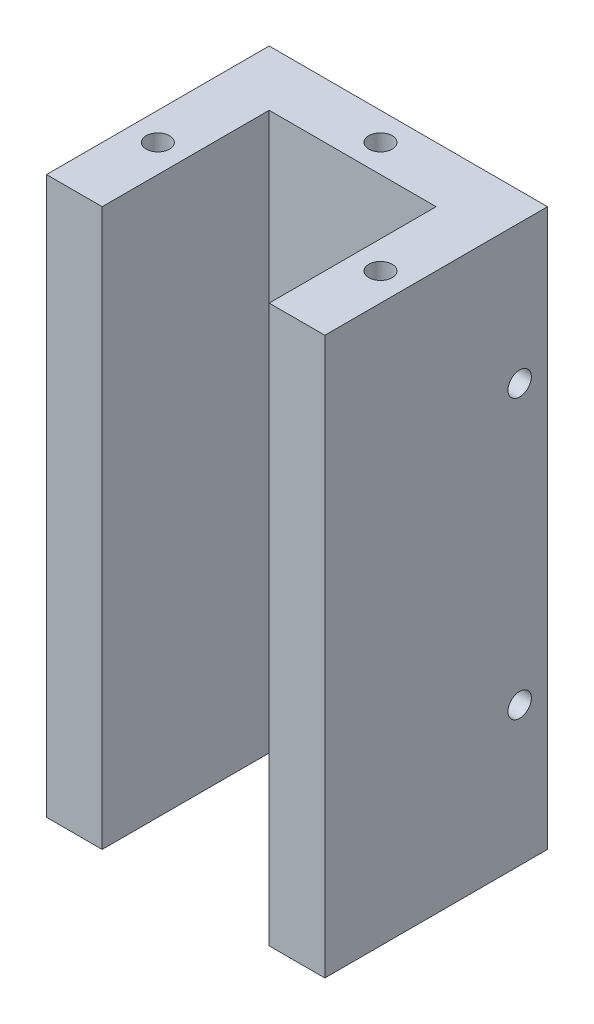
from build123d import *

# Parameters (mm, degrees)
SKETCH1_W                 = 50
SKETCH1_H                 = 40
BOSS_EXTRUDE1_DEPTH       = 100
SKETCH2_W                 = 30
SKETCH2_H                 = 30
CUT_EXTRUDE1_DEPTH        = 100
SKETCH3_R                 = 3.5
CUT_EXTRUDE2_DEPTH        = 10
M5X0_8_TAPPED_HOLE1_D     = 4.2
M5X0_8_TAPPED_HOLE1_DEPTH = 14
M5X0_8_TAPPED_HOLE1_TIP   = 1.2618073
M5X0_8_TAPPED_HOLE2_D     = 4.2
M5X0_8_TAPPED_HOLE2_DEPTH = 14
M5X0_8_TAPPED_HOLE2_TIP   = 1.2618073
M5X0_8_TAPPED_HOLE3_D     = 4.2
M5X0_8_TAPPED_HOLE3_DEPTH = 14
M5X0_8_TAPPED_HOLE3_TIP   = 1.2618073
M5X0_8_TAPPED_HOLE4_D     = 4.2
M5X0_8_TAPPED_HOLE4_DEPTH = 14
M5X0_8_TAPPED_HOLE4_TIP   = 1.2618073


with BuildPart() as part:
    # Sketch1 → Boss-Extrude1 (new body)
    with BuildSketch(Plane(origin=(0, 0, 0), x_dir=(1, 0, 0), z_dir=(0, 1, 0))):
        Rectangle(SKETCH1_W, SKETCH1_H)
    extrude(amount=BOSS_EXTRUDE1_DEPTH)

    # Sketch2 → Cut-Extrude1 (cut)
    with BuildSketch(Plane(origin=(0, 100, 0), x_dir=(1, 0, 0), z_dir=(0, 1, 0))):
        with Locations((0, -5)):
            Rectangle(SKETCH2_W, SKETCH2_H)
    extrude(amount=-CUT_EXTRUDE1_DEPTH, mode=Mode.SUBTRACT)

    # Sketch3 → Cut-Extrude2 (cut)
    with BuildSketch(Plane(origin=(0, 0, -20), x_dir=(-1, 0, 0), z_dir=(0, 0, -1))):
        with Locations((0, 25)):
            Circle(SKETCH3_R)
        with Locations((0, 75)):
            Circle(SKETCH3_R)
    extrude(amount=-CUT_EXTRUDE2_DEPTH, mode=Mode.SUBTRACT)

    # M5x0.8 Tapped Hole1
    with Locations(Plane.XZ):
        with Locations((0, -15), (-20, 5), (20, 5)):
            Hole(M5X0_8_TAPPED_HOLE1_D / 2, depth=M5X0_8_TAPPED_HOLE1_DEPTH)
            with Locations((0, 0, -(M5X0_8_TAPPED_HOLE1_DEPTH + M5X0_8_TAPPED_HOLE1_TIP / 2))):  # 118° drill point
                Cone(0, M5X0_8_TAPPED_HOLE1_D / 2, M5X0_8_TAPPED_HOLE1_TIP, mode=Mode.SUBTRACT)

    # M5x0.8 Tapped Hole2
    with Locations(Plane(origin=(0, 100, 0), x_dir=(-1, 0, 0), z_dir=(0, 1, 0))):
        with Locations((20, 5), (-20, 5), (0, -15)):
            Hole(M5X0_8_TAPPED_HOLE2_D / 2, depth=M5X0_8_TAPPED_HOLE2_DEPTH)
            with Locations((0, 0, -(M5X0_8_TAPPED_HOLE2_DEPTH + M5X0_8_TAPPED_HOLE2_TIP / 2))):  # 118° drill point
                Cone(0, M5X0_8_TAPPED_HOLE2_D / 2, M5X0_8_TAPPED_HOLE2_TIP, mode=Mode.SUBTRACT)

    # M5x0.8 Tapped Hole3
    with Locations(Plane(origin=(25, 0, 0), x_dir=(0, 0, -1), z_dir=(1, 0, 0))):
        with Locations((15, 75), (15, 25)):
            Hole(M5X0_8_TAPPED_HOLE3_D / 2, depth=M5X0_8_TAPPED_HOLE3_DEPTH)
            with Locations((0, 0, -(M5X0_8_TAPPED_HOLE3_DEPTH + M5X0_8_TAPPED_HOLE3_TIP / 2))):  # 118° drill point
                Cone(0, M5X0_8_TAPPED_HOLE3_D / 2, M5X0_8_TAPPED_HOLE3_TIP, mode=Mode.SUBTRACT)

    # M5x0.8 Tapped Hole4
    with Locations(Plane.ZY.offset(25)):
        with Locations((-15, 75), (-15, 25)):
            Hole(M5X0_8_TAPPED_HOLE4_D / 2, depth=M5X0_8_TAPPED_HOLE4_DEPTH)
            with Locations((0, 0, -(M5X0_8_TAPPED_HOLE4_DEPTH + M5X0_8_TAPPED_HOLE4_TIP / 2))):  # 118° drill point
                Cone(0, M5X0_8_TAPPED_HOLE4_D / 2, M5X0_8_TAPPED_HOLE4_TIP, mode=Mode.SUBTRACT)


solid = part.part
